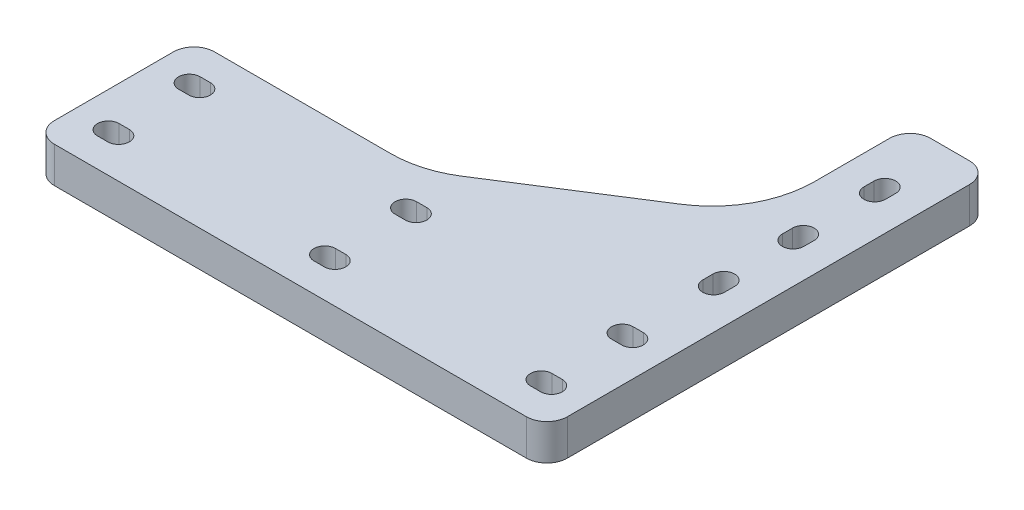
from build123d import *

# Parameters (mm, degrees)
BOSS_EXTRUDE2_DEPTH = 8.89


with BuildPart() as part:
    # Sketch1 → Boss-Extrude2 (new body)
    with BuildSketch(Plane(origin=(0, 0, 0), x_dir=(1, 0, 0), z_dir=(0, 1, 0))):
        with BuildLine():
            Line((58.42, -19.812), (-58.42, -19.812))
            ThreePointArc((-58.42, -19.812), (-62.012102448, -18.324102448), (-63.5, -14.732))
            Line((-63.5, -14.732), (-63.5, 14.732))
            ThreePointArc((-63.5, 14.732), (-62.012102448, 18.324102448), (-58.42, 19.812))
            Line((-58.42, 19.812), (-14.766931822, 19.812))
            ThreePointArc((-14.766931822, 19.812), (-7.661480975, 20.826090785), (-1.123398019, 23.787388326))
            Line((-1.123398019, 23.787388326), (31.931533802, 44.837295158))
            ThreePointArc((31.931533802, 44.837295158), (40.555754249, 54.042777538), (43.688, 66.261906832))
            Line((43.688, 66.261906832), (43.688, 84.836))
            ThreePointArc((43.688, 84.836), (45.175897552, 88.428102448), (48.768, 89.916))
            Line((48.768, 89.916), (58.42, 89.916))
            ThreePointArc((58.42, 89.916), (62.012102448, 88.428102448), (63.5, 84.836))
            Line((63.5, 84.836), (63.5, 14.732))
            Line((63.5, 14.732), (63.5, -14.732))
            ThreePointArc((63.5, -14.732), (62.012102448, -18.324102448), (58.42, -19.812))
        make_face()
        with BuildLine():
            Line((56.261, 73.787), (56.261, 71.247))
            ThreePointArc((56.261, 71.247), (53.594, 68.58), (50.927, 71.247))
            Line((50.927, 71.247), (50.927, 73.787))
            ThreePointArc((50.927, 73.787), (53.594, 76.454), (56.261, 73.787))
        make_face(mode=Mode.SUBTRACT)
        with BuildLine():
            Line((50.927, 51.054), (50.927, 53.594))
            ThreePointArc((50.927, 53.594), (53.594, 56.261), (56.261, 53.594))
            Line((56.261, 53.594), (56.261, 51.054))
            ThreePointArc((56.261, 51.054), (53.594, 48.387), (50.927, 51.054))
        make_face(mode=Mode.SUBTRACT)
        with BuildLine():
            Line((50.927, 31.369), (50.927, 33.909))
            ThreePointArc((50.927, 33.909), (53.594, 36.576), (56.261, 33.909))
            Line((56.261, 33.909), (56.261, 31.369))
            ThreePointArc((56.261, 31.369), (53.594, 28.702), (50.927, 31.369))
        make_face(mode=Mode.SUBTRACT)
        with BuildLine():
            Line((-54.864, -7.366), (-52.324, -7.366))
            ThreePointArc((-52.324, -7.366), (-49.657, -10.033), (-52.324, -12.7))
            Line((-52.324, -12.7), (-54.864, -12.7))
            ThreePointArc((-54.864, -12.7), (-57.531, -10.033), (-54.864, -7.366))
        make_face(mode=Mode.SUBTRACT)
        with BuildLine():
            Line((54.864, -12.7), (52.324, -12.7))
            ThreePointArc((52.324, -12.7), (49.657, -10.033), (52.324, -7.366))
            Line((52.324, -7.366), (54.864, -7.366))
            ThreePointArc((54.864, -7.366), (57.531, -10.033), (54.864, -12.7))
        make_face(mode=Mode.SUBTRACT)
        with BuildLine():
            Line((-1.27, -7.366), (1.27, -7.366))
            ThreePointArc((1.27, -7.366), (3.937, -10.033), (1.27, -12.7))
            Line((1.27, -12.7), (-1.27, -12.7))
            ThreePointArc((-1.27, -12.7), (-3.937, -10.033), (-1.27, -7.366))
        make_face(mode=Mode.SUBTRACT)
        with BuildLine():
            Line((-54.864, 7.366), (-52.324, 7.366))
            ThreePointArc((-52.324, 7.366), (-49.657, 10.033), (-52.324, 12.7))
            Line((-52.324, 12.7), (-54.864, 12.7))
            ThreePointArc((-54.864, 12.7), (-57.531, 10.033), (-54.864, 7.366))
        make_face(mode=Mode.SUBTRACT)
        with BuildLine():
            Line((54.864, 12.7), (52.324, 12.7))
            ThreePointArc((52.324, 12.7), (49.657, 10.033), (52.324, 7.366))
            Line((52.324, 7.366), (54.864, 7.366))
            ThreePointArc((54.864, 7.366), (57.531, 10.033), (54.864, 12.7))
        make_face(mode=Mode.SUBTRACT)
        with BuildLine():
            Line((-1.27, 7.366), (1.27, 7.366))
            ThreePointArc((1.27, 7.366), (3.937, 10.033), (1.27, 12.7))
            Line((1.27, 12.7), (-1.27, 12.7))
            ThreePointArc((-1.27, 12.7), (-3.937, 10.033), (-1.27, 7.366))
        make_face(mode=Mode.SUBTRACT)
    extrude(amount=BOSS_EXTRUDE2_DEPTH)


solid = part.part
